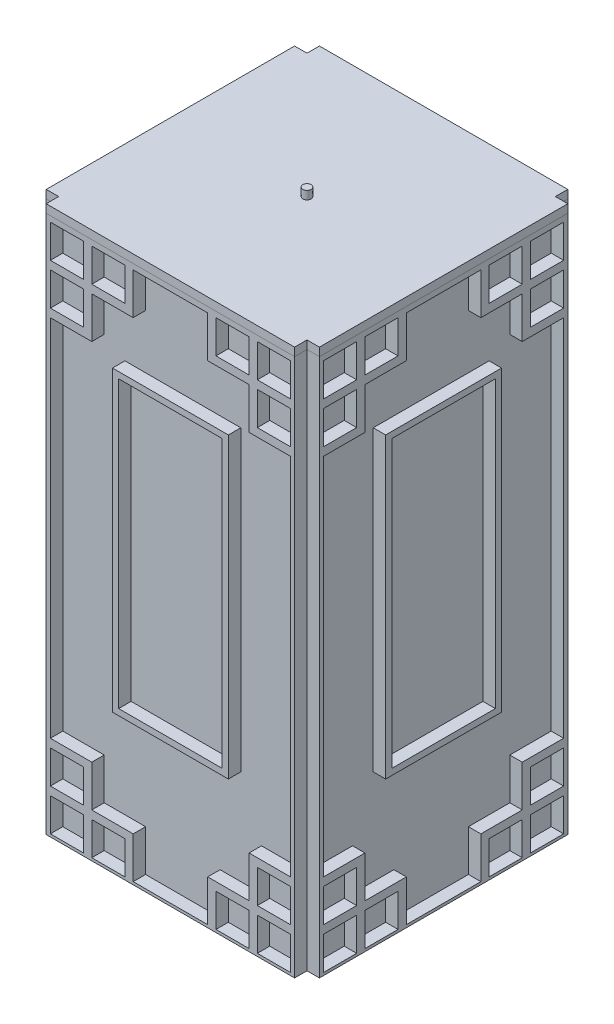
from build123d import *

# Parameters (mm, degrees)
SKETCH_1_W                 = 300
SKETCH_1_H                 = 300
EXTRUDE_1_DEPTH            = 650
SHELL_1_T                  = -10
SKETCH_6_W                 = 300
SKETCH_6_H                 = 650
SKETCH_6_W_2               = 40
SKETCH_6_H_2               = 40
EXTRUDE_2_DEPTH            = 15
SKETCH_7_W                 = 140
SKETCH_7_H                 = 360
SKETCH_7_W_2               = 125
SKETCH_7_H_2               = 345
EXTRUDE_3_DEPTH            = 15
MIRROR_5_COPY_1_SKETCH_W   = 300
MIRROR_5_COPY_1_SKETCH_H   = 650
MIRROR_5_COPY_1_SKETCH_W_2 = 40
MIRROR_5_COPY_1_SKETCH_H_2 = 40
MIRROR_5_COPY_1_DEPTH      = 15
MIRROR_5_COPY_2_SKETCH_W   = 140
MIRROR_5_COPY_2_SKETCH_H   = 360
MIRROR_5_COPY_2_SKETCH_W_2 = 125
MIRROR_5_COPY_2_SKETCH_H_2 = 345
MIRROR_5_COPY_2_DEPTH      = 15
MIRROR_5_COPY_3_SKETCH_W   = 300
MIRROR_5_COPY_3_SKETCH_H   = 650
MIRROR_5_COPY_3_SKETCH_W_2 = 40
MIRROR_5_COPY_3_SKETCH_H_2 = 40
MIRROR_5_COPY_3_DEPTH      = 15
MIRROR_5_COPY_4_SKETCH_W   = 140
MIRROR_5_COPY_4_SKETCH_H   = 360
MIRROR_5_COPY_4_SKETCH_W_2 = 125
MIRROR_5_COPY_4_SKETCH_H_2 = 345
MIRROR_5_COPY_4_DEPTH      = 15
EXTRUDE_4_DEPTH            = 10
SKETCH_15_R                = 5
EXTRUDE_5_DEPTH            = 10


with BuildPart() as part:
    # 草图1 → 凸台-拉伸1 (new body)
    with BuildSketch(Plane(origin=(0, 0, 0), x_dir=(1, 0, 0), z_dir=(0, 1, 0))):
        Rectangle(SKETCH_1_W, SKETCH_1_H)
    extrude(amount=EXTRUDE_1_DEPTH)

    # 抽壳1
    shell_1_openings = [part.faces().sort_by_distance(p)[0] for p in [
        (0, 0, 0),
    ]]
    offset(amount=SHELL_1_T, openings=shell_1_openings, kind=Kind.INTERSECTION)

    # 草图6 → 凸台-拉伸2 (add)
    with BuildSketch(Plane.XY.offset(150)):
        with Locations((0, 325)):
            Rectangle(SKETCH_6_W, SKETCH_6_H)
        with Locations((-75, 623.299592936)):
            Rectangle(SKETCH_6_W_2, SKETCH_6_H_2, mode=Mode.SUBTRACT)
        with Locations((-125, 623.299592936)):
            Rectangle(SKETCH_6_W_2, SKETCH_6_H_2, mode=Mode.SUBTRACT)
        with Locations((-75, 23.299592936)):
            Rectangle(SKETCH_6_W_2, SKETCH_6_H_2, mode=Mode.SUBTRACT)
        with Locations((125, 623.299592936)):
            Rectangle(SKETCH_6_W_2, SKETCH_6_H_2, mode=Mode.SUBTRACT)
        with Locations((-125, 573.299592936)):
            Rectangle(SKETCH_6_W_2, SKETCH_6_H_2, mode=Mode.SUBTRACT)
        Polygon((-95, 543.299592936), (-145, 543.299592936), (-145, 103.299592936), (-95, 103.299592936), (-95, 53.299592936), (-45, 53.299592936), (-45, 3.299592936), (45, 3.299592936), (45, 53.299592936), (95, 53.299592936), (95, 103.299592936), (145, 103.299592936), (145, 543.299592936), (95, 543.299592936), (95, 593.299592936), (45, 593.299592936), (45, 643.299592936), (-45, 643.299592936), (-45, 593.299592936), (-95, 593.299592936), align=None, mode=Mode.SUBTRACT)
        with Locations((75, 623.299592936)):
            Rectangle(SKETCH_6_W_2, SKETCH_6_H_2, mode=Mode.SUBTRACT)
        with Locations((125, 573.299592936)):
            Rectangle(SKETCH_6_W_2, SKETCH_6_H_2, mode=Mode.SUBTRACT)
        with Locations((125, 73.299592936)):
            Rectangle(SKETCH_6_W_2, SKETCH_6_H_2, mode=Mode.SUBTRACT)
        with Locations((125, 23.299592936)):
            Rectangle(SKETCH_6_W_2, SKETCH_6_H_2, mode=Mode.SUBTRACT)
        with Locations((75, 23.299592936)):
            Rectangle(SKETCH_6_W_2, SKETCH_6_H_2, mode=Mode.SUBTRACT)
        with Locations((-125, 73.299592936)):
            Rectangle(SKETCH_6_W_2, SKETCH_6_H_2, mode=Mode.SUBTRACT)
        with Locations((-125, 23.299592936)):
            Rectangle(SKETCH_6_W_2, SKETCH_6_H_2, mode=Mode.SUBTRACT)
    extrude_2 = extrude(amount=EXTRUDE_2_DEPTH)

    # 草图7 → 凸台-拉伸3 (add)
    with BuildSketch(Plane.XY.offset(150)):
        with Locations((0, 348.11476684)):
            Rectangle(SKETCH_7_W, SKETCH_7_H)
        with Locations((0, 348.11476684)):
            Rectangle(SKETCH_7_W_2, SKETCH_7_H_2, mode=Mode.SUBTRACT)
    extrude_3 = extrude(amount=EXTRUDE_3_DEPTH)

    # 镜向1: 凸台-拉伸2, 凸台-拉伸3 across plane
    add(extrude_2.mirror(Plane(origin=(0, 0, 0), x_dir=(1, 0, 0), z_dir=(0, 0, -1))))
    add(extrude_3.mirror(Plane(origin=(0, 0, 0), x_dir=(1, 0, 0), z_dir=(0, 0, -1))))

    # 镜向3: 凸台-拉伸2, 凸台-拉伸3 across plane
    add(extrude_2.mirror(Plane(origin=(0, 0, 0), x_dir=(0.707106781, 0, 0.707106781), z_dir=(-0.707106781, 0, 0.707106781))))
    add(extrude_3.mirror(Plane(origin=(0, 0, 0), x_dir=(0.707106781, 0, 0.707106781), z_dir=(-0.707106781, 0, 0.707106781))))

    # 镜向5 copy 1 sketch → 镜向5 copy 1 (add)
    with BuildSketch(Plane.ZY.offset(150)):
        with Locations((0, 325)):
            Rectangle(MIRROR_5_COPY_1_SKETCH_W, MIRROR_5_COPY_1_SKETCH_H)
        with Locations((-75, 623.299592936)):
            Rectangle(MIRROR_5_COPY_1_SKETCH_W_2, MIRROR_5_COPY_1_SKETCH_H_2, mode=Mode.SUBTRACT)
        with Locations((-125, 623.299592936)):
            Rectangle(MIRROR_5_COPY_1_SKETCH_W_2, MIRROR_5_COPY_1_SKETCH_H_2, mode=Mode.SUBTRACT)
        with Locations((-75, 23.299592936)):
            Rectangle(MIRROR_5_COPY_1_SKETCH_W_2, MIRROR_5_COPY_1_SKETCH_H_2, mode=Mode.SUBTRACT)
        with Locations((125, 623.299592936)):
            Rectangle(MIRROR_5_COPY_1_SKETCH_W_2, MIRROR_5_COPY_1_SKETCH_H_2, mode=Mode.SUBTRACT)
        with Locations((-125, 573.299592936)):
            Rectangle(MIRROR_5_COPY_1_SKETCH_W_2, MIRROR_5_COPY_1_SKETCH_H_2, mode=Mode.SUBTRACT)
        Polygon((-95, 543.299592936), (-145, 543.299592936), (-145, 103.299592936), (-95, 103.299592936), (-95, 53.299592936), (-45, 53.299592936), (-45, 3.299592936), (45, 3.299592936), (45, 53.299592936), (95, 53.299592936), (95, 103.299592936), (145, 103.299592936), (145, 543.299592936), (95, 543.299592936), (95, 593.299592936), (45, 593.299592936), (45, 643.299592936), (-45, 643.299592936), (-45, 593.299592936), (-95, 593.299592936), align=None, mode=Mode.SUBTRACT)
        with Locations((75, 623.299592936)):
            Rectangle(MIRROR_5_COPY_1_SKETCH_W_2, MIRROR_5_COPY_1_SKETCH_H_2, mode=Mode.SUBTRACT)
        with Locations((125, 573.299592936)):
            Rectangle(MIRROR_5_COPY_1_SKETCH_W_2, MIRROR_5_COPY_1_SKETCH_H_2, mode=Mode.SUBTRACT)
        with Locations((125, 73.299592936)):
            Rectangle(MIRROR_5_COPY_1_SKETCH_W_2, MIRROR_5_COPY_1_SKETCH_H_2, mode=Mode.SUBTRACT)
        with Locations((125, 23.299592936)):
            Rectangle(MIRROR_5_COPY_1_SKETCH_W_2, MIRROR_5_COPY_1_SKETCH_H_2, mode=Mode.SUBTRACT)
        with Locations((75, 23.299592936)):
            Rectangle(MIRROR_5_COPY_1_SKETCH_W_2, MIRROR_5_COPY_1_SKETCH_H_2, mode=Mode.SUBTRACT)
        with Locations((-125, 73.299592936)):
            Rectangle(MIRROR_5_COPY_1_SKETCH_W_2, MIRROR_5_COPY_1_SKETCH_H_2, mode=Mode.SUBTRACT)
        with Locations((-125, 23.299592936)):
            Rectangle(MIRROR_5_COPY_1_SKETCH_W_2, MIRROR_5_COPY_1_SKETCH_H_2, mode=Mode.SUBTRACT)
    extrude(amount=MIRROR_5_COPY_1_DEPTH)

    # 镜向5 copy 2 sketch → 镜向5 copy 2 (add)
    with BuildSketch(Plane.ZY.offset(150)):
        with Locations((0, 348.11476684)):
            Rectangle(MIRROR_5_COPY_2_SKETCH_W, MIRROR_5_COPY_2_SKETCH_H)
        with Locations((0, 348.11476684)):
            Rectangle(MIRROR_5_COPY_2_SKETCH_W_2, MIRROR_5_COPY_2_SKETCH_H_2, mode=Mode.SUBTRACT)
    extrude(amount=MIRROR_5_COPY_2_DEPTH)

    # 镜向5 copy 3 sketch → 镜向5 copy 3 (add)
    with BuildSketch(Plane(origin=(0, 0, 150), x_dir=(-1, 0, 0), z_dir=(0, 0, 1))):
        with Locations((0, -325)):
            Rectangle(MIRROR_5_COPY_3_SKETCH_W, MIRROR_5_COPY_3_SKETCH_H)
        with Locations((-75, -623.299592936)):
            Rectangle(MIRROR_5_COPY_3_SKETCH_W_2, MIRROR_5_COPY_3_SKETCH_H_2, mode=Mode.SUBTRACT)
        with Locations((-125, -623.299592936)):
            Rectangle(MIRROR_5_COPY_3_SKETCH_W_2, MIRROR_5_COPY_3_SKETCH_H_2, mode=Mode.SUBTRACT)
        with Locations((-75, -23.299592936)):
            Rectangle(MIRROR_5_COPY_3_SKETCH_W_2, MIRROR_5_COPY_3_SKETCH_H_2, mode=Mode.SUBTRACT)
        with Locations((125, -623.299592936)):
            Rectangle(MIRROR_5_COPY_3_SKETCH_W_2, MIRROR_5_COPY_3_SKETCH_H_2, mode=Mode.SUBTRACT)
        with Locations((-125, -573.299592936)):
            Rectangle(MIRROR_5_COPY_3_SKETCH_W_2, MIRROR_5_COPY_3_SKETCH_H_2, mode=Mode.SUBTRACT)
        Polygon((-95, -543.299592936), (-145, -543.299592936), (-145, -103.299592936), (-95, -103.299592936), (-95, -53.299592936), (-45, -53.299592936), (-45, -3.299592936), (45, -3.299592936), (45, -53.299592936), (95, -53.299592936), (95, -103.299592936), (145, -103.299592936), (145, -543.299592936), (95, -543.299592936), (95, -593.299592936), (45, -593.299592936), (45, -643.299592936), (-45, -643.299592936), (-45, -593.299592936), (-95, -593.299592936), align=None, mode=Mode.SUBTRACT)
        with Locations((75, -623.299592936)):
            Rectangle(MIRROR_5_COPY_3_SKETCH_W_2, MIRROR_5_COPY_3_SKETCH_H_2, mode=Mode.SUBTRACT)
        with Locations((125, -573.299592936)):
            Rectangle(MIRROR_5_COPY_3_SKETCH_W_2, MIRROR_5_COPY_3_SKETCH_H_2, mode=Mode.SUBTRACT)
        with Locations((125, -73.299592936)):
            Rectangle(MIRROR_5_COPY_3_SKETCH_W_2, MIRROR_5_COPY_3_SKETCH_H_2, mode=Mode.SUBTRACT)
        with Locations((125, -23.299592936)):
            Rectangle(MIRROR_5_COPY_3_SKETCH_W_2, MIRROR_5_COPY_3_SKETCH_H_2, mode=Mode.SUBTRACT)
        with Locations((75, -23.299592936)):
            Rectangle(MIRROR_5_COPY_3_SKETCH_W_2, MIRROR_5_COPY_3_SKETCH_H_2, mode=Mode.SUBTRACT)
        with Locations((-125, -73.299592936)):
            Rectangle(MIRROR_5_COPY_3_SKETCH_W_2, MIRROR_5_COPY_3_SKETCH_H_2, mode=Mode.SUBTRACT)
        with Locations((-125, -23.299592936)):
            Rectangle(MIRROR_5_COPY_3_SKETCH_W_2, MIRROR_5_COPY_3_SKETCH_H_2, mode=Mode.SUBTRACT)
    extrude(amount=MIRROR_5_COPY_3_DEPTH)

    # 镜向5 copy 4 sketch → 镜向5 copy 4 (add)
    with BuildSketch(Plane(origin=(0, 0, 150), x_dir=(-1, 0, 0), z_dir=(0, 0, 1))):
        with Locations((0, -348.11476684)):
            Rectangle(MIRROR_5_COPY_4_SKETCH_W, MIRROR_5_COPY_4_SKETCH_H)
        with Locations((0, -348.11476684)):
            Rectangle(MIRROR_5_COPY_4_SKETCH_W_2, MIRROR_5_COPY_4_SKETCH_H_2, mode=Mode.SUBTRACT)
    extrude(amount=MIRROR_5_COPY_4_DEPTH)


with BuildPart() as body_2:
    # 草图14 → 凸台-拉伸4 (new body)
    with BuildSketch(Plane(origin=(0, 660, 0), x_dir=(1, 0, 0), z_dir=(0, 1, 0))):
        Polygon((-150, 165), (-150, 150), (-165, 150), (-165, -150), (-150, -150), (-150, -165), (150, -165), (150, -150), (165, -150), (165, 150), (150, 150), (150, 165), align=None)
    extrude(amount=-EXTRUDE_4_DEPTH)

    # 草图15 → 凸台-拉伸5 (add)
    with BuildSketch(Plane(origin=(0, 660, 0), x_dir=(1, 0, 0), z_dir=(0, 1, 0))):
        Circle(SKETCH_15_R)
    extrude(amount=EXTRUDE_5_DEPTH)


solid = Compound([part.part, body_2.part])
